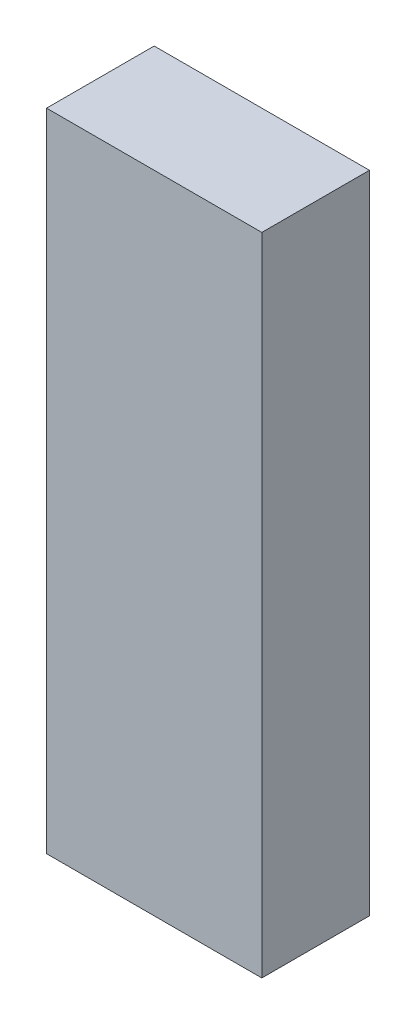
from build123d import *

# Parameters (mm, degrees)
SKETCH1_W           = 10
SKETCH1_H           = 30
BOSS_EXTRUDE1_DEPTH = 5


with BuildPart() as part:
    # Sketch1 → Boss-Extrude1 (new body)
    with BuildSketch(Plane.XY):
        with Locations((5, 15)):
            Rectangle(SKETCH1_W, SKETCH1_H)
    extrude(amount=BOSS_EXTRUDE1_DEPTH)


solid = part.part
